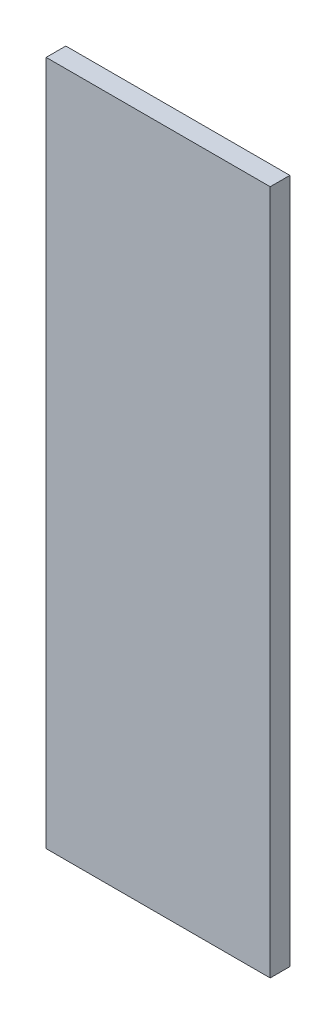
from build123d import *

# Parameters (mm, degrees)
SKETCH1_W           = 205
SKETCH1_H           = 627
BOSS_EXTRUDE1_DEPTH = 18


with BuildPart() as part:
    # Sketch1 → Boss-Extrude1 (new body)
    with BuildSketch(Plane.XY):
        Rectangle(SKETCH1_W, SKETCH1_H)
    extrude(amount=BOSS_EXTRUDE1_DEPTH)


solid = part.part
